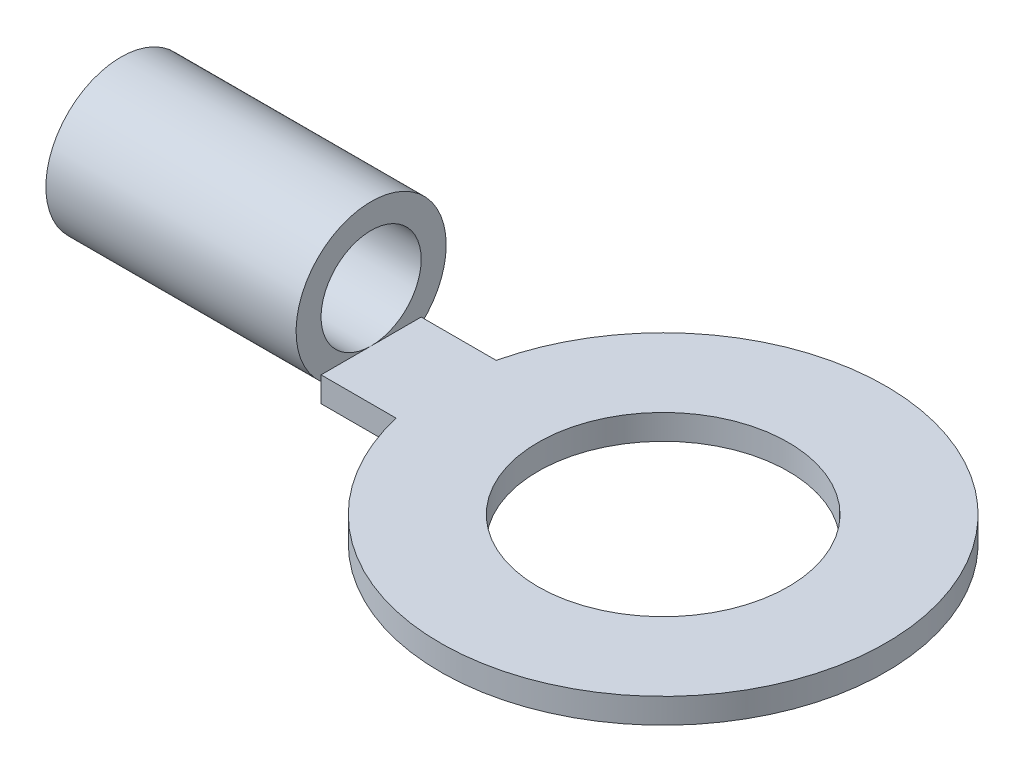
from build123d import *

# Parameters (mm, degrees)
SKETCH1_R           = 2.5
BOSS_EXTRUDE1_DEPTH = 0.5
SKETCH2_R           = 1.5
SKETCH2_R_2         = 1
BOSS_EXTRUDE2_DEPTH = 5


with BuildPart() as part:
    # Sketch1 → Boss-Extrude1 (new body)
    with BuildSketch(Plane(origin=(0, 0, 0), x_dir=(1, 0, 0), z_dir=(0, 1, 0))):
        with BuildLine():
            Line((0, -1), (0, 1))
            Line((0, 1), (1.5, 1))
            ThreePointArc((1.5, 1), (10.286184959, 0), (1.5, -1))
            Line((1.5, -1), (0, -1))
        make_face()
        with Locations((5.836184959, 0)):
            Circle(SKETCH1_R, mode=Mode.SUBTRACT)
    extrude(amount=BOSS_EXTRUDE1_DEPTH)

    # Sketch2 → Boss-Extrude2 (add)
    with BuildSketch(Plane(origin=(0, 0, 0), x_dir=(0, 0, -1), z_dir=(1, 0, 0))):
        with Locations((0, 1.5)):
            Circle(SKETCH2_R)
        with Locations((0, 1.5)):
            Circle(SKETCH2_R_2, mode=Mode.SUBTRACT)
    extrude(amount=-BOSS_EXTRUDE2_DEPTH)


solid = part.part
